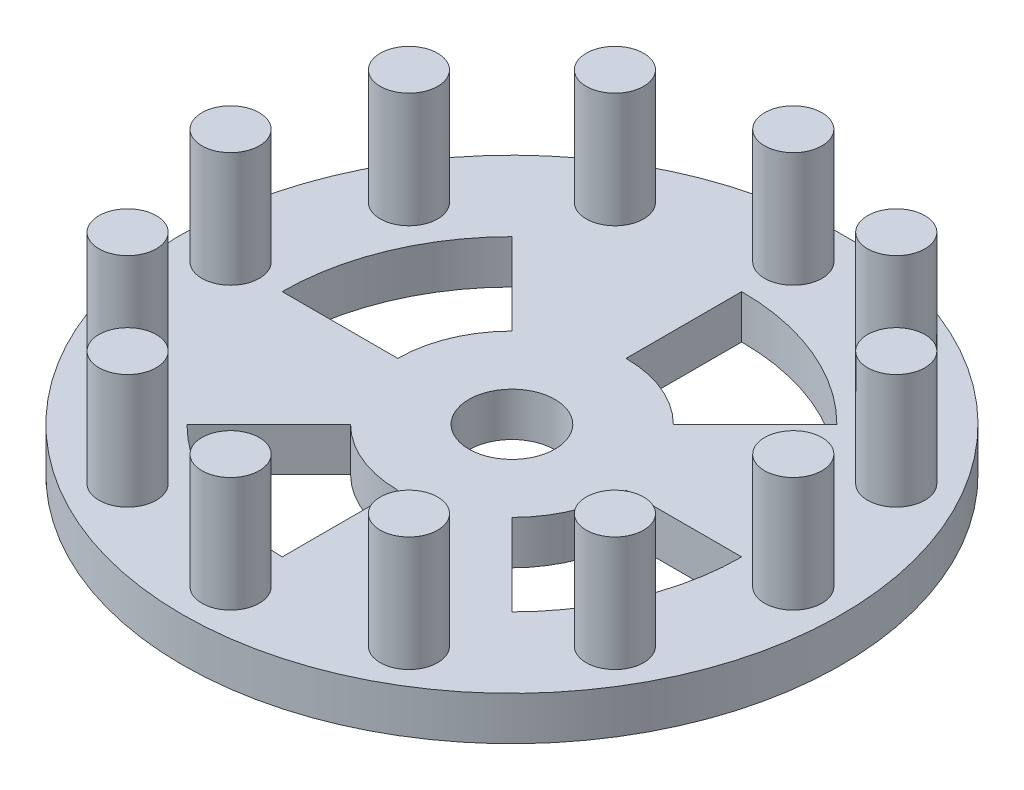
from build123d import *

# Parameters (mm, degrees)
SKETCH1_R         = 36.449
SKETCH1_R_2       = 4.7625
EXTRUDE1_DEPTH    = 4.826
SKETCH2_R         = 3.175
EXTRUDE2_DEPTH    = 12.7
CIRPATTERN1_COUNT = 12
EXTRUDE3_DEPTH    = 19.05
CIRPATTERN2_COUNT = 4


with BuildPart() as part:
    # Sketch1 → Extrude1 (new body)
    with BuildSketch(Plane(origin=(0, 0, 0), x_dir=(1, 0, 0), z_dir=(0, 1, 0))):
        with Locations(Location((31.896411717, 77.004913135, 0), (0, 0, 270))):  # turned: the seam where the file's is
            Circle(SKETCH1_R)
        with Locations(Location((31.896411717, 77.004913135, 0), (0, 0, 270))):  # turned: the seam where the file's is
            Circle(SKETCH1_R_2, mode=Mode.SUBTRACT)
    extrude(amount=EXTRUDE1_DEPTH)

    # Sketch2 → Extrude2 (add)
    with BuildSketch(Plane(origin=(0, 4.826, 0), x_dir=(1, 0, 0), z_dir=(0, 1, 0))):
        with Locations(Location((63.011411717, 77.004913135, 0), (0, 0, 270))):  # turned: the seam where the file's is
            Circle(SKETCH2_R)
    extrude2 = extrude(amount=EXTRUDE2_DEPTH)

    # CirPattern1: Extrude2 ×12 about axis
    cirpattern1_axis = Axis((31.896411717, 0, -77.004913135), (0, 1, 0))
    for i in range(1, CIRPATTERN1_COUNT):
        add(extrude2.rotate(cirpattern1_axis, i * 360 / CIRPATTERN1_COUNT))

    # Sketch3 → Extrude3 (cut)
    with BuildSketch(Plane(origin=(0, 4.826, 0), x_dir=(1, 0, 0), z_dir=(0, 1, 0))):
        with BuildLine():
            Line((31.896411717, 89.62444152), (31.896411717, 102.416748175))
            ThreePointArc((31.896411717, 102.416748175), (41.621099973, 100.482387412), (49.865292596, 94.973794014))
            Line((49.865292596, 94.973794014), (40.819765813, 85.928267231))
            ThreePointArc((40.819765813, 85.928267231), (36.725696154, 88.66383712), (31.896411717, 89.62444152))
        make_face()
    extrude3 = extrude(amount=-EXTRUDE3_DEPTH, mode=Mode.SUBTRACT)

    # CirPattern2: Extrude3 ×4 about axis
    cirpattern2_axis = Axis((31.896411717, 4.826, -77.004913135), (0, 1, 0))
    for i in range(1, CIRPATTERN2_COUNT):
        add(extrude3.rotate(cirpattern2_axis, i * 360 / CIRPATTERN2_COUNT), mode=Mode.SUBTRACT)


solid = part.part
